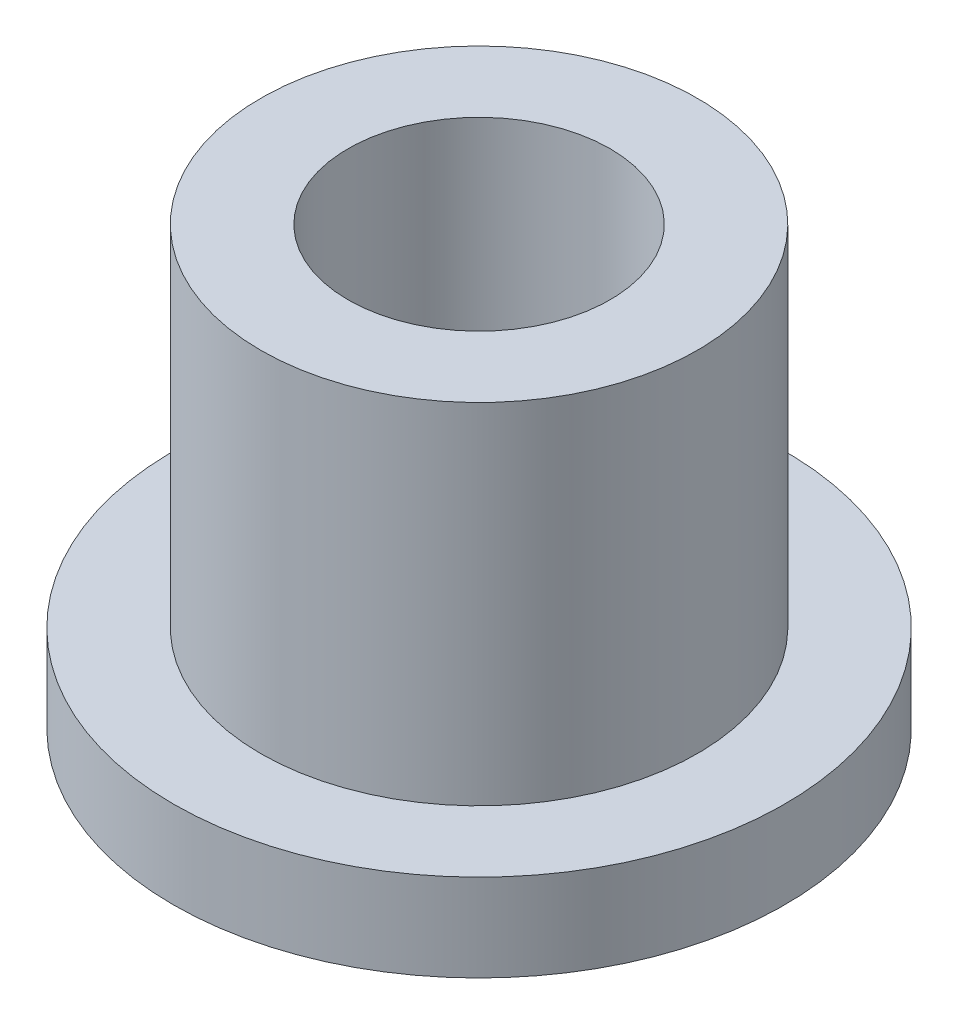
from build123d import *

# Parameters (mm, degrees)
SKETCH2_R           = 5
SKETCH2_R_2         = 3
BOSS_EXTRUDE1_DEPTH = 10
SKETCH3_R           = 7
SKETCH3_R_2         = 5
BOSS_EXTRUDE2_DEPTH = 2


with BuildPart() as part:
    # Sketch2 → Boss-Extrude1 (new body)
    with BuildSketch(Plane(origin=(0, 0, 0), x_dir=(1, 0, 0), z_dir=(0, 1, 0))):
        Circle(SKETCH2_R)
        Circle(SKETCH2_R_2, mode=Mode.SUBTRACT)
    extrude(amount=BOSS_EXTRUDE1_DEPTH)

    # Sketch3 → Boss-Extrude2 (add)
    with BuildSketch(Plane(origin=(0, 0, 0), x_dir=(1, 0, 0), z_dir=(0, 1, 0))):
        Circle(SKETCH3_R)
        Circle(SKETCH3_R_2, mode=Mode.SUBTRACT)
    extrude(amount=BOSS_EXTRUDE2_DEPTH)


solid = part.part
